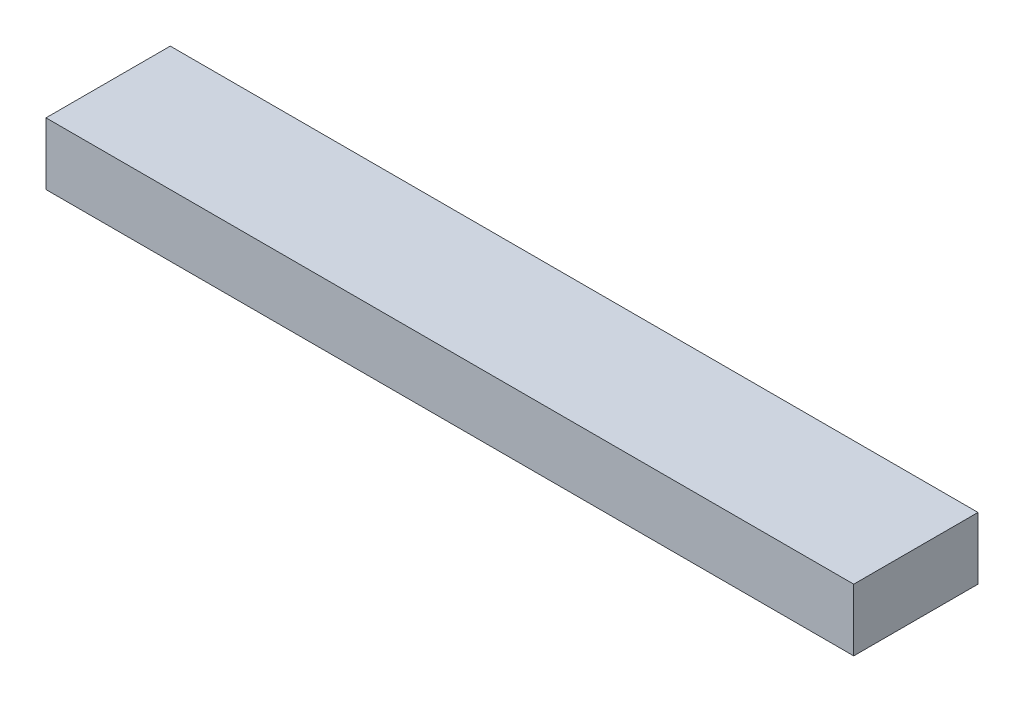
from build123d import *

# Parameters (mm, degrees)
SKETCH1_W           = 65
SKETCH1_H           = 10
BOSS_EXTRUDE1_DEPTH = 5


with BuildPart() as part:
    # Sketch1 → Boss-Extrude1 (new body)
    with BuildSketch(Plane(origin=(0, 0, 0), x_dir=(1, 0, 0), z_dir=(0, 1, 0))):
        Rectangle(SKETCH1_W, SKETCH1_H)
    extrude(amount=BOSS_EXTRUDE1_DEPTH)


solid = part.part
